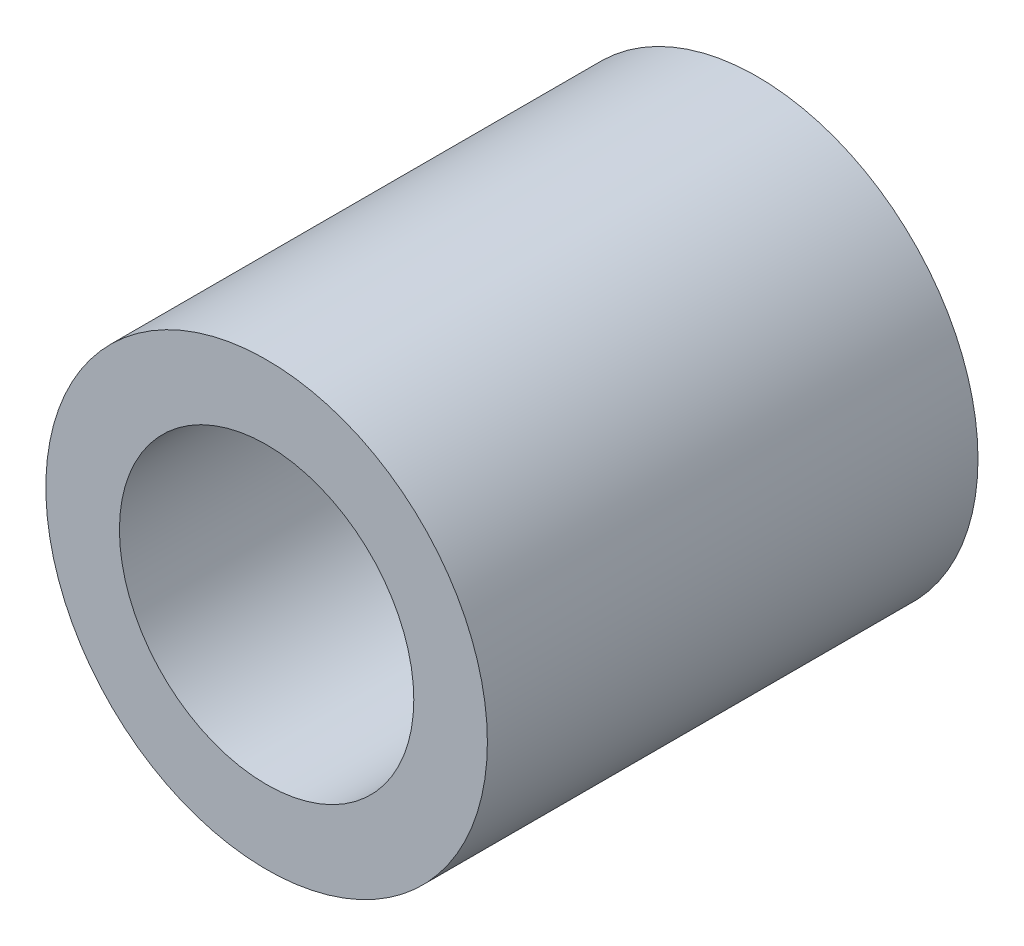
from build123d import *

# Parameters (mm, degrees)
SKETCH1_R           = 2.25
SKETCH1_R_2         = 1.5
BOSS_EXTRUDE1_DEPTH = 2.5


with BuildPart() as part:
    # Sketch1 → Boss-Extrude1 (new body, symmetric)
    with BuildSketch(Plane.XY):
        Circle(SKETCH1_R)
        Circle(SKETCH1_R_2, mode=Mode.SUBTRACT)
    extrude(amount=BOSS_EXTRUDE1_DEPTH, both=True)


solid = part.part
